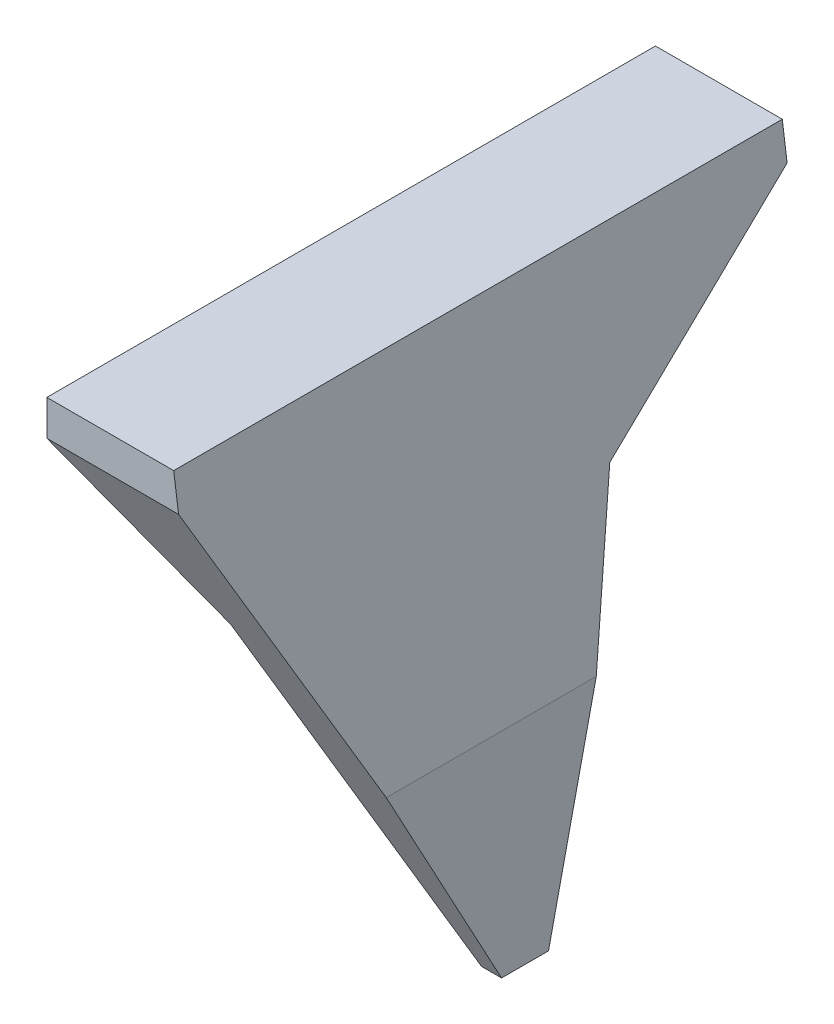
from build123d import *

# Parameters (mm, degrees)
SKETCH_1_W               = 20
SKETCH_1_H               = 70
EXTRUDE_1_DEPTH          = 68
SKETCH_2_W               = 10.341057985
SKETCH_2_H               = 14.244474777
CUT_EXTRUDE_1_DEPTH      = 66.5
CUT_EXTRUDE_2_DEPTH      = 27
CUT_EXTRUDE_2_DEPTH_BACK = 28.5
CUT_EXTRUDE_3_DEPTH      = 18
CUT_EXTRUDE_3_DEPTH_BACK = 80.5


with BuildPart() as part:
    # 草图1 → 凸台-拉伸1 (new body)
    with BuildSketch(Plane(origin=(0, 0, 0), x_dir=(1, 0, 0), z_dir=(0, 1, 0))):
        Rectangle(SKETCH_1_W, SKETCH_1_H)
    extrude(amount=EXTRUDE_1_DEPTH)

    # 草图2 → 切除-拉伸1 (cut)
    with BuildSketch(Plane.XZ):
        with Locations((-3.329471008, -0.802163256)):
            Rectangle(SKETCH_2_W, SKETCH_2_H)
    extrude(amount=-CUT_EXTRUDE_1_DEPTH, mode=Mode.SUBTRACT)

    # 草图3 → 切除-拉伸2 (cut, two sides)
    with BuildSketch(Plane.ZY.offset(10)) as cut_extrude_2_sk:
        Polygon((-35, 68), (-35, 63.923584322), (-12.228951857, 46.66952319), (-2.701261913, 4.015150281), (2.701261913, 4.015150281), (35, 63.923584322), (35, 68), (43.781903243, 68), (43.781903243, -5.043476458), (-39.089851198, -5.043476458), (-39.089851198, 68), align=None)
    extrude(amount=CUT_EXTRUDE_2_DEPTH, mode=Mode.SUBTRACT)
    extrude(cut_extrude_2_sk.sketch, amount=-CUT_EXTRUDE_2_DEPTH_BACK, mode=Mode.SUBTRACT)

    # 草图4 → 切除-拉伸3 (cut, two sides)
    with BuildSketch(Plane(origin=(0, 0, -35), x_dir=(-1, 0, 0), z_dir=(0, 0, -1))) as cut_extrude_3_sk:
        Polygon((-10, 28.610295414), (-5.14861474, 63.923584322), (-10, 63.923584322), align=None)
        Polygon((-5.14861474, 63.923584322), (-4.588591487, 68), (-10, 68), (-10, 63.923584322), align=None)
        Polygon((-7.700970851, -1.077719905), (-7.700970851, 4.015150281), (-1.841057985, 46.66952319), (10, 63.923584322), (16.463180064, 63.923584322), (16.463180064, -1.077719905), align=None)
    extrude(amount=CUT_EXTRUDE_3_DEPTH, mode=Mode.SUBTRACT)
    extrude(cut_extrude_3_sk.sketch, amount=-CUT_EXTRUDE_3_DEPTH_BACK, mode=Mode.SUBTRACT)


solid = part.part
